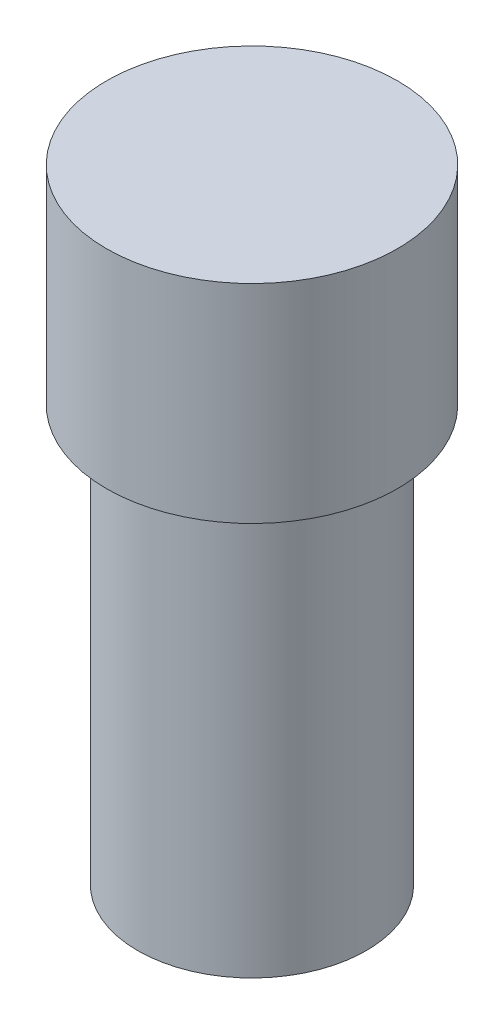
from build123d import *

# Parameters (mm, degrees)
SKETCH1_R           = 2.75
BOSS_EXTRUDE1_DEPTH = 10
SKETCH2_R           = 3.5
BOSS_EXTRUDE2_DEPTH = 5


with BuildPart() as part:
    # Sketch1 → Boss-Extrude1 (new body)
    with BuildSketch(Plane(origin=(0, 0, 0), x_dir=(1, 0, 0), z_dir=(0, 1, 0))):
        Circle(SKETCH1_R)
    extrude(amount=BOSS_EXTRUDE1_DEPTH)

    # Sketch2 → Boss-Extrude2 (add)
    with BuildSketch(Plane(origin=(0, 10, 0), x_dir=(1, 0, 0), z_dir=(0, 1, 0))):
        Circle(SKETCH2_R)
    extrude(amount=BOSS_EXTRUDE2_DEPTH)


solid = part.part
